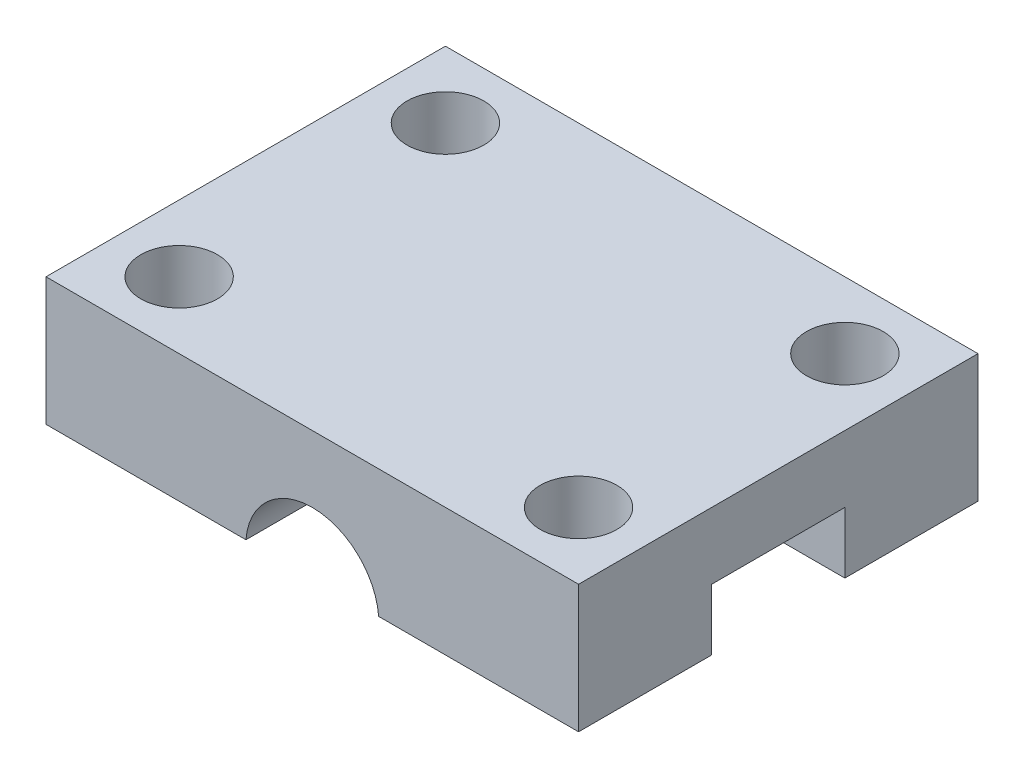
from build123d import *

# Parameters (mm, degrees)
BOSS_EXTRUDE1_DEPTH = 25.4
SKETCH2_R           = 3.175
CUT_EXTRUDE2_DEPTH  = 20.05
SKETCH4_R           = 1.8288
CUT_EXTRUDE3_DEPTH  = 7.096


with BuildPart() as part:
    # Sketch1 → Boss-Extrude1 (new body)
    with BuildSketch(Plane(origin=(0, 0, 0), x_dir=(0, 0, -1), z_dir=(1, 0, 0))):
        Polygon((0, 6.096), (0, 0), (6.35, 0), (6.35, 2.921), (12.7, 2.921), (12.7, 0), (19.05, 0), (19.05, 6.096), align=None)
    extrude(amount=BOSS_EXTRUDE1_DEPTH)

    # Sketch2 → Cut-Extrude2 (cut, through all)
    with BuildSketch(Plane.XY):
        with Locations((12.7, -0.254)):
            Circle(SKETCH2_R)
    extrude(amount=-CUT_EXTRUDE2_DEPTH, mode=Mode.SUBTRACT)

    # Sketch4 → Cut-Extrude3 (cut, through all)
    with BuildSketch(Plane.XZ):
        with Locations((3.175, -3.175)):
            Circle(SKETCH4_R)
        with Locations((3.175, -15.875)):
            Circle(SKETCH4_R)
        with Locations((22.225, -3.175)):
            Circle(SKETCH4_R)
        with Locations((22.225, -15.875)):
            Circle(SKETCH4_R)
    extrude(amount=-CUT_EXTRUDE3_DEPTH, mode=Mode.SUBTRACT)


solid = part.part
